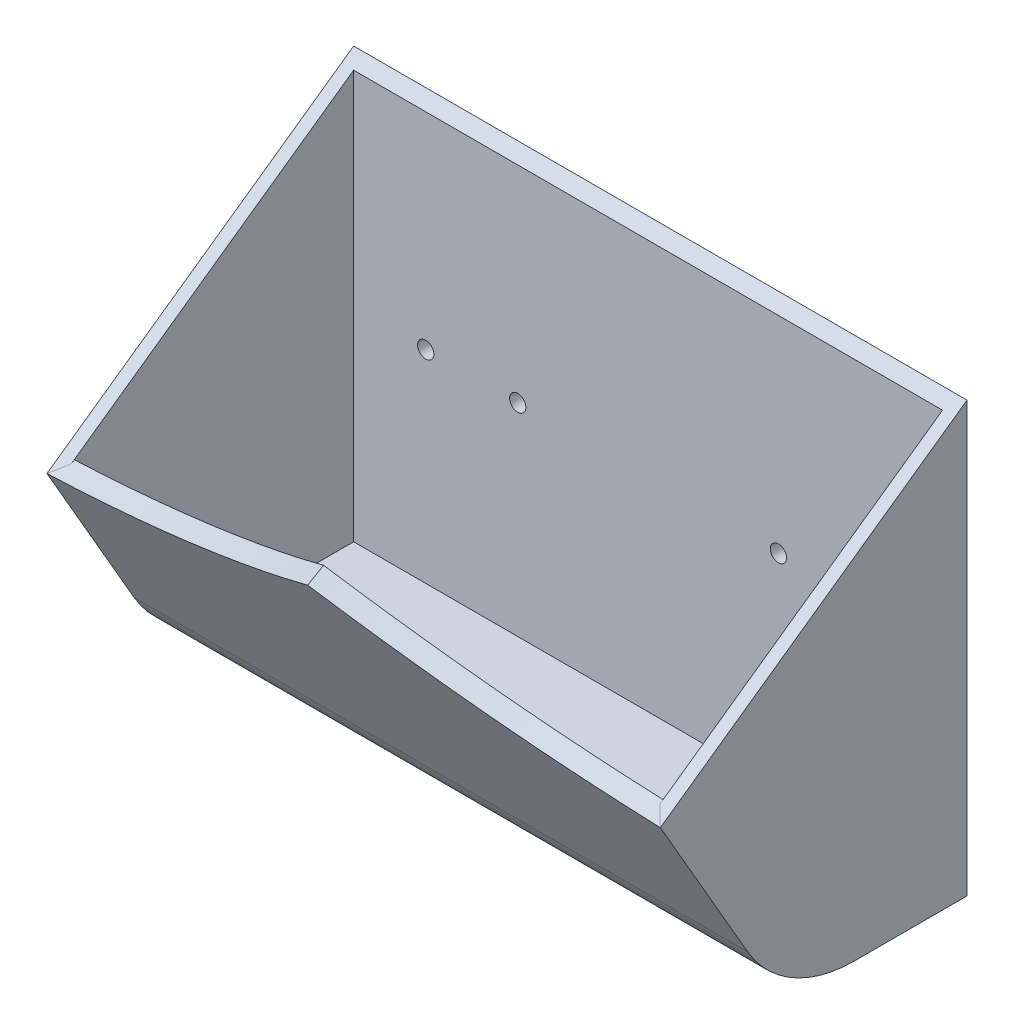
from build123d import *

# Parameters (mm, degrees)
BOSS_EXTRUDE1_DEPTH = 63.5
FILLET1_R           = 25.4
SHELL1_T            = -2.54
BOSS_EXTRUDE4_DEPTH = 3.81
CUT_EXTRUDE2_REACH  = 75.025
SKETCH6_R           = 1.6891


with BuildPart() as part:
    # Sketch2 → Boss-Extrude1 (new body, symmetric)
    with BuildSketch(Plane(origin=(0, 0, 0), x_dir=(0, 0, -1), z_dir=(1, 0, 0))):
        Polygon((0, 50.8), (0, -38.1), (-38.1, -38.1), (-63.5, 5.894090512), align=None)
    extrude(amount=BOSS_EXTRUDE1_DEPTH, both=True)

    # Fillet1
    fillet1_edges = [part.edges().sort_by_distance(p)[0] for p in [
        (0, -38.1, 38.1),
    ]]
    fillet(fillet1_edges, radius=FILLET1_R)

    # Shell1
    shell1_openings = [part.faces().sort_by_distance(p)[0] for p in [
        (0, 28.347045256, 31.75),
    ]]
    offset(amount=SHELL1_T, openings=shell1_openings, kind=Kind.INTERSECTION)

    # Sketch3 → Boss-Extrude4 (add)
    with BuildSketch(Plane(origin=(0, -26.022783942, 45.072783942), x_dir=(1, 0, 0), z_dir=(0, -0.5, 0.866025404))):
        with BuildLine():
            Line((-63.5, 36.854432116), (63.5, 36.854432116))
            ThreePointArc((63.5, 36.854432116), (30.854255532, 43.393617223), (0, 55.904432116))
            ThreePointArc((0, 55.904432116), (-30.854255532, 43.393617223), (-63.5, 36.854432116))
        make_face()
    extrude(amount=-BOSS_EXTRUDE4_DEPTH)

    # Sketch6 → Cut-Extrude2 (cut, up to next)
    with BuildSketch(Plane(origin=(0, 0, 0), x_dir=(-1, 0, 0), z_dir=(0, 0, -1)), mode=Mode.PRIVATE) as cut_extrude2_sk1:
        with Locations((-46.0375, 6.35)):
            Circle(SKETCH6_R)
    cut_extrude2_tool1 = extrude(cut_extrude2_sk1.sketch, amount=-CUT_EXTRUDE2_REACH, mode=Mode.PRIVATE) & part.part
    add(cut_extrude2_tool1.solids().sort_by_distance((46.0375, 6.35, 0))[0], mode=Mode.SUBTRACT)
    # Sketch6 → Cut-Extrude2 (cut, up to next)
    with BuildSketch(Plane(origin=(0, 0, 0), x_dir=(-1, 0, 0), z_dir=(0, 0, -1)), mode=Mode.PRIVATE) as cut_extrude2_sk2:
        with Locations((-26.9875, 6.35)):
            Circle(SKETCH6_R)
    cut_extrude2_tool2 = extrude(cut_extrude2_sk2.sketch, amount=-CUT_EXTRUDE2_REACH, mode=Mode.PRIVATE) & part.part
    add(cut_extrude2_tool2.solids().sort_by_distance((26.9875, 6.35, 0))[0], mode=Mode.SUBTRACT)
    # Sketch6 → Cut-Extrude2 (cut, up to next)
    with BuildSketch(Plane(origin=(0, 0, 0), x_dir=(-1, 0, 0), z_dir=(0, 0, -1)), mode=Mode.PRIVATE) as cut_extrude2_sk3:
        with Locations((26.9875, 6.35)):
            Circle(SKETCH6_R)
    cut_extrude2_tool3 = extrude(cut_extrude2_sk3.sketch, amount=-CUT_EXTRUDE2_REACH, mode=Mode.PRIVATE) & part.part
    add(cut_extrude2_tool3.solids().sort_by_distance((-26.9875, 6.35, 0))[0], mode=Mode.SUBTRACT)
    # Sketch6 → Cut-Extrude2 (cut, up to next)
    with BuildSketch(Plane(origin=(0, 0, 0), x_dir=(-1, 0, 0), z_dir=(0, 0, -1)), mode=Mode.PRIVATE) as cut_extrude2_sk4:
        with Locations((46.0375, 6.35)):
            Circle(SKETCH6_R)
    cut_extrude2_tool4 = extrude(cut_extrude2_sk4.sketch, amount=-CUT_EXTRUDE2_REACH, mode=Mode.PRIVATE) & part.part
    add(cut_extrude2_tool4.solids().sort_by_distance((-46.0375, 6.35, 0))[0], mode=Mode.SUBTRACT)


solid = part.part
